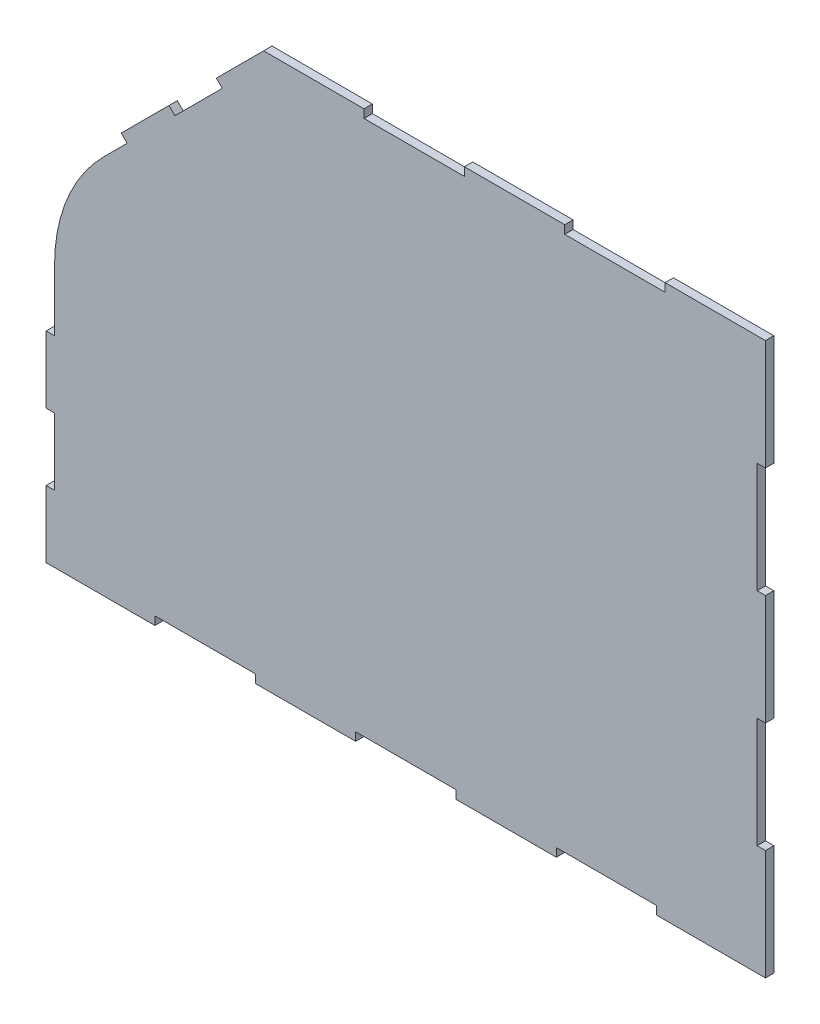
from build123d import *

# Parameters (mm, degrees)
BOSS_EXTRU_1_DEPTH      = 5
ENL_V_MAT_EXTRU_1_REACH = 7


with BuildPart() as part:
    # Esquisse1 → Boss.-Extru.1 (new body)
    with BuildSketch(Plane.XY):
        Polygon((0, 330), (-60, 330), (-60, 325), (-120, 325), (-120, 330), (-180, 330), (-180, 325), (-240, 325), (-240, 330), (-300, 330), (-328.284271247, 301.715728753), (-324.748737342, 298.180194847), (-353.033008589, 269.895923599), (-356.568542495, 273.431457505), (-399.901875828, 230.098124172), (-396.366341922, 226.562590266), (-411.415404008, 211.51352818), (-414.950937914, 215.049062086), (-430, 200), (-430, 160), (-425, 160), (-425, 120), (-430, 120), (-430, 80), (-425, 80), (-425, 40), (-430, 40), (-430, 0), (-365, 0), (-365, 5), (-305, 5), (-305, 0), (-245, 0), (-245, 5), (-185, 5), (-185, 0), (-125, 0), (-125, 5), (-65, 5), (-65, 0), (0, 0), (0, 66), (-5, 66), (-5, 132), (0, 132), (0, 198), (-5, 198), (-5, 264), (0, 264), align=None)
    extrude(amount=BOSS_EXTRU_1_DEPTH)

    # Esquisse2 → Enlèv. mat.-Extru.1 (cut, up to next)
    with BuildSketch(Plane.XY.offset(5), mode=Mode.PRIVATE) as enl_v_mat_extru_1_sk1:
        with BuildLine():
            Line((-395.710678119, 227.218254069), (-381.568542495, 241.360389693))
            Line((-381.568542495, 241.360389693), (-385.104076401, 244.895923599))
            Line((-385.104076401, 244.895923599), (-430, 200))
            Line((-430, 200), (-430, 156.507575951))
            Line((-430, 156.507575951), (-425, 156.507575951))
            ThreePointArc((-425, 156.507575951), (-417.387953251, 194.775919187), (-395.710678119, 227.218254069))
        make_face()
    enl_v_mat_extru_1_tool1 = extrude(enl_v_mat_extru_1_sk1.sketch, amount=-ENL_V_MAT_EXTRU_1_REACH, mode=Mode.PRIVATE) & part.part
    add(enl_v_mat_extru_1_tool1.solids().sort_by_distance((-415.711514, 201.173028, 5))[0], mode=Mode.SUBTRACT)


solid = part.part
